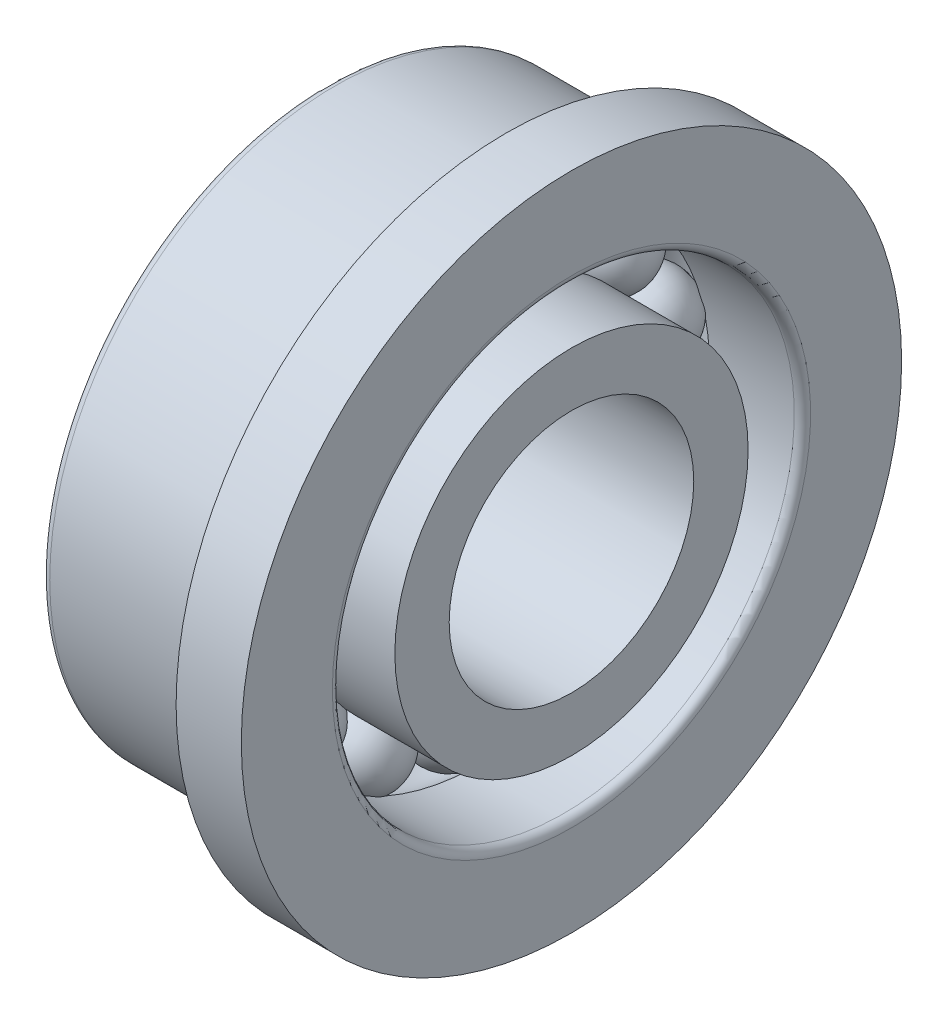
from build123d import *

# Parameters (mm, degrees)
CIRCULAR_PATTERN1_COUNT = 14
FILLET1_R               = 0.1


with BuildPart() as part:
    # Sketch1 → Revolve1 (revolve)
    with BuildSketch(Plane.XY):
        with BuildLine():
            Line((-0.5, 2.5), (0.5, 2.5))
            ThreePointArc((0.5, 2.5), (0, 2), (-0.5, 2.5))
        make_face()
    revolve1 = revolve(axis=Axis((-0.807148311, 2.5, 0), (1, 0, 0)))

    # Sketch2 → Revolve2 (revolve)
    with BuildSketch(Plane.XY, mode=Mode.PRIVATE) as revolve2_sk:
        with BuildLine():
            Line((-1.5, 2.166666667), (-0.359150232, 2.166666667))
            ThreePointArc((-0.359150232, 2.166666667), (0, 2.01), (0.359150232, 2.166666667))
            Line((0.359150232, 2.166666667), (1.5, 2.166666667))
            Line((1.5, 2.166666667), (1.5, 1.5))
            Line((1.5, 1.5), (-1.5, 1.5))
            Line((-1.5, 1.5), (-1.5, 2.166666667))
        make_face()
    revolve(revolve2_sk.sketch.rotate(Axis((-0.841709544, 0, 0), (1, 0, 0)), 90), axis=Axis((-0.841709544, 0, 0), (1, 0, 0)))

    # Sketch3 → Revolve3 (revolve)
    with BuildSketch(Plane.XY, mode=Mode.PRIVATE) as revolve3_sk:
        with BuildLine():
            Line((-1.5, 3.5), (-1.5, 2.833333333))
            Line((-1.5, 2.833333333), (-0.359150232, 2.833333333))
            ThreePointArc((-0.359150232, 2.833333333), (0, 2.99), (0.359150232, 2.833333333))
            Line((0.359150232, 2.833333333), (1.5, 2.833333333))
            Line((1.5, 2.833333333), (1.5, 4.05))
            Line((1.5, 4.05), (0.7, 4.05))
            Line((0.7, 4.05), (0.7, 3.5275))
            ThreePointArc((0.7, 3.5275), (0.719445436, 3.480554564), (0.6725, 3.5))
            Line((0.6725, 3.5), (-1.5, 3.5))
        make_face()
    revolve(revolve3_sk.sketch.rotate(Axis((-0.999715665, 0, 0), (1, 0, 0)), 90), axis=Axis((-0.999715665, 0, 0), (1, 0, 0)))

    # Circular-Pattern1: Revolve1 ×14 about axis
    circular_pattern1_axis = Axis((0, 0, 0), (1, 0, 0))
    for i in range(1, CIRCULAR_PATTERN1_COUNT):
        add(revolve1.rotate(circular_pattern1_axis, i * 360 / CIRCULAR_PATTERN1_COUNT))

    # Fillet1
    fillet1_edges = [part.edges().sort_by_distance(p)[0] for p in [
        (-1.5, 0, -3.5),
        (1.5, 0, -2.833333333),
        (-1.5, 0, -1.5),
    ]]
    fillet(fillet1_edges, radius=FILLET1_R)


solid = part.part
